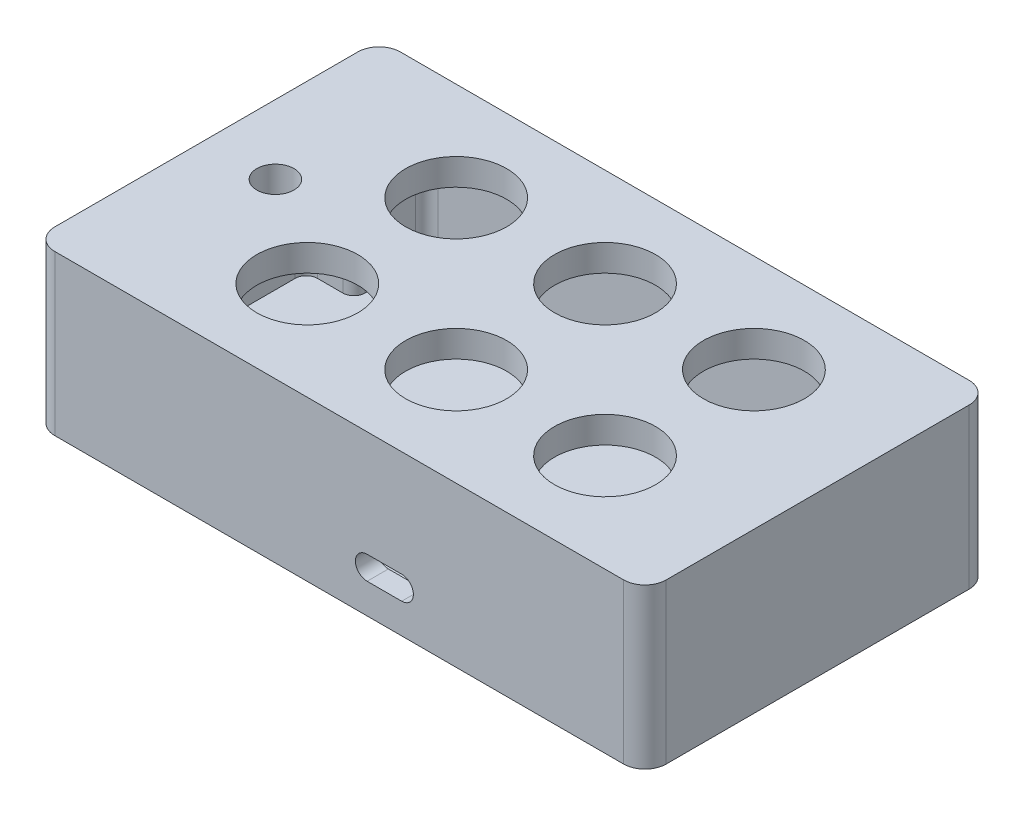
from build123d import *

# Parameters (mm, degrees)
SKETCH1_W           = 115
SKETCH1_H           = 65
SKETCH1_R           = 2.1
BOSS_EXTRUDE1_DEPTH = 22
BOSS_EXTRUDE4_START = 3
SKETCH6_W           = 115
SKETCH6_H           = 65
SKETCH6_R           = 2.1
BOSS_EXTRUDE4_DEPTH = 3
SKETCH7_W           = 115
SKETCH7_H           = 65
BOSS_EXTRUDE5_DEPTH = 5
FILLET1_R           = 4
CUT_EXTRUDE1_REACH  = 137.462
SKETCH4_R           = 9.5
SKETCH4_R_2         = 3.5
CUT_EXTRUDE2_REACH  = 136.83


with BuildPart() as part:
    # Sketch1 → Boss-Extrude1 (new body)
    with BuildSketch(Plane(origin=(0, 0, 0), x_dir=(1, 0, 0), z_dir=(0, 1, 0))):
        with Locations((57.5, 32.5)):
            Rectangle(SKETCH1_W, SKETCH1_H)
        with Locations((108.9, 50.001511105)):
            Circle(SKETCH1_R, mode=Mode.SUBTRACT)
        with Locations((110.685057222, 6.404275632)):
            Circle(SKETCH1_R, mode=Mode.SUBTRACT)
        with Locations((7.785057222, 14.601511105)):
            Circle(SKETCH1_R, mode=Mode.SUBTRACT)
        with Locations((7.785057222, 55.601511105)):
            Circle(SKETCH1_R, mode=Mode.SUBTRACT)
        with BuildLine():
            Line((6.1, 47.31447682), (10.861715208, 47.31447682))
            ThreePointArc((10.861715208, 47.31447682), (12.346639448, 47.929552579), (12.961715208, 49.41447682))
            Line((12.961715208, 49.41447682), (12.961715208, 58.9))
            ThreePointArc((12.961715208, 58.9), (13.576790967, 60.38492424), (15.061715208, 61))
            Line((15.061715208, 61), (100.622896336, 61))
            ThreePointArc((100.622896336, 61), (102.107820577, 60.38492424), (102.722896336, 58.9))
            Line((102.722896336, 58.9), (102.722896336, 44.601511105))
            ThreePointArc((102.722896336, 44.601511105), (103.337972096, 43.116586864), (104.822896336, 42.501511105))
            Line((104.822896336, 42.501511105), (108.9, 42.501511105))
            ThreePointArc((108.9, 42.501511105), (110.38492424, 41.886435345), (111, 40.401511105))
            Line((111, 40.401511105), (111, 14.601511105))
            ThreePointArc((111, 14.601511105), (110.38492424, 13.116586864), (108.9, 12.501511105))
            Line((108.9, 12.501511105), (105.206624477, 12.501511105))
            ThreePointArc((105.206624477, 12.501511105), (103.721700237, 11.886435345), (103.106624477, 10.401511105))
            Line((103.106624477, 10.401511105), (103.106624477, 6.1))
            ThreePointArc((103.106624477, 6.1), (102.491548718, 4.61507576), (101.006624477, 4))
            Line((101.006624477, 4), (18.206624477, 4))
            ThreePointArc((18.206624477, 4), (16.721700237, 4.61507576), (16.106624477, 6.1))
            Line((16.106624477, 6.1), (16.106624477, 19.183092127))
            ThreePointArc((16.106624477, 19.183092127), (15.491548718, 20.668016368), (14.006624477, 21.283092127))
            Line((14.006624477, 21.283092127), (6.1, 21.283092127))
            ThreePointArc((6.1, 21.283092127), (4.61507576, 21.898167887), (4, 23.383092127))
            Line((4, 23.383092127), (4, 45.21447682))
            ThreePointArc((4, 45.21447682), (4.61507576, 46.69940106), (6.1, 47.31447682))
        make_face(mode=Mode.SUBTRACT)
    extrude(amount=BOSS_EXTRUDE1_DEPTH)

    # Sketch6 → Boss-Extrude4 (add)
    with BuildSketch(Plane.XZ.offset(BOSS_EXTRUDE4_START)):
        with Locations((57.5, -32.5)):
            Rectangle(SKETCH6_W, SKETCH6_H)
        with Locations((7.785057222, -55.601511105)):
            Circle(SKETCH6_R, mode=Mode.SUBTRACT)
        with Locations((108.9, -50.001511105)):
            Circle(SKETCH6_R, mode=Mode.SUBTRACT)
        with Locations((7.785057222, -14.601511105)):
            Circle(SKETCH6_R, mode=Mode.SUBTRACT)
        with Locations((110.685057222, -6.404275632)):
            Circle(SKETCH6_R, mode=Mode.SUBTRACT)
    extrude(amount=-BOSS_EXTRUDE4_DEPTH)

    # Sketch7 → Boss-Extrude5 (add)
    with BuildSketch(Plane(origin=(0, 22, 0), x_dir=(1, 0, 0), z_dir=(0, 1, 0))):
        with Locations((57.5, 32.5)):
            Rectangle(SKETCH7_W, SKETCH7_H)
    extrude(amount=BOSS_EXTRUDE5_DEPTH)

    # Fillet1
    fillet1_edges = [part.edges().sort_by_distance(p)[0] for p in [
        (0, 12, -65),
        (115, 12, -65),
        (115, 12, 0),
        (0, 12, 0),
    ]]
    fillet(fillet1_edges, radius=FILLET1_R)

    # Sketch4 → Cut-Extrude1 (cut, up to next)
    with BuildSketch(Plane(origin=(0, 27, 0), x_dir=(1, 0, 0), z_dir=(0, 1, 0)), mode=Mode.PRIVATE) as cut_extrude1_sk1:
        with Locations((33, 46.5)):
            Circle(SKETCH4_R)
    cut_extrude1_tool1 = extrude(cut_extrude1_sk1.sketch, amount=-CUT_EXTRUDE1_REACH, mode=Mode.PRIVATE) & part.part
    # Sketch4 → Cut-Extrude1 (cut, up to next)
    with BuildSketch(Plane(origin=(0, 27, 0), x_dir=(1, 0, 0), z_dir=(0, 1, 0)), mode=Mode.PRIVATE) as cut_extrude1_sk2:
        with Locations((33, 18.5)):
            Circle(SKETCH4_R)
    cut_extrude1_tool2 = extrude(cut_extrude1_sk2.sketch, amount=-CUT_EXTRUDE1_REACH, mode=Mode.PRIVATE) & part.part
    # Sketch4 → Cut-Extrude1 (cut, up to next)
    with BuildSketch(Plane(origin=(0, 27, 0), x_dir=(1, 0, 0), z_dir=(0, 1, 0)), mode=Mode.PRIVATE) as cut_extrude1_sk3:
        with Locations((61, 46.5)):
            Circle(SKETCH4_R)
    cut_extrude1_tool3 = extrude(cut_extrude1_sk3.sketch, amount=-CUT_EXTRUDE1_REACH, mode=Mode.PRIVATE) & part.part
    # Sketch4 → Cut-Extrude1 (cut, up to next)
    with BuildSketch(Plane(origin=(0, 27, 0), x_dir=(1, 0, 0), z_dir=(0, 1, 0)), mode=Mode.PRIVATE) as cut_extrude1_sk4:
        with Locations((89, 46.5)):
            Circle(SKETCH4_R)
    cut_extrude1_tool4 = extrude(cut_extrude1_sk4.sketch, amount=-CUT_EXTRUDE1_REACH, mode=Mode.PRIVATE) & part.part
    # Sketch4 → Cut-Extrude1 (cut, up to next)
    with BuildSketch(Plane(origin=(0, 27, 0), x_dir=(1, 0, 0), z_dir=(0, 1, 0)), mode=Mode.PRIVATE) as cut_extrude1_sk5:
        with Locations((61, 18.5)):
            Circle(SKETCH4_R)
    cut_extrude1_tool5 = extrude(cut_extrude1_sk5.sketch, amount=-CUT_EXTRUDE1_REACH, mode=Mode.PRIVATE) & part.part
    # Sketch4 → Cut-Extrude1 (cut, up to next)
    with BuildSketch(Plane(origin=(0, 27, 0), x_dir=(1, 0, 0), z_dir=(0, 1, 0)), mode=Mode.PRIVATE) as cut_extrude1_sk6:
        with Locations((89, 18.5)):
            Circle(SKETCH4_R)
    cut_extrude1_tool6 = extrude(cut_extrude1_sk6.sketch, amount=-CUT_EXTRUDE1_REACH, mode=Mode.PRIVATE) & part.part
    # Sketch4 → Cut-Extrude1 (cut, up to next)
    with BuildSketch(Plane(origin=(0, 27, 0), x_dir=(1, 0, 0), z_dir=(0, 1, 0)), mode=Mode.PRIVATE) as cut_extrude1_sk7:
        with Locations((13, 32.5)):
            Circle(SKETCH4_R_2)
    cut_extrude1_tool7 = extrude(cut_extrude1_sk7.sketch, amount=-CUT_EXTRUDE1_REACH, mode=Mode.PRIVATE) & part.part
    add(cut_extrude1_tool1.solids().sort_by_distance((33, 27, -46.5))[0], mode=Mode.SUBTRACT)
    add(cut_extrude1_tool2.solids().sort_by_distance((33, 27, -18.5))[0], mode=Mode.SUBTRACT)
    add(cut_extrude1_tool3.solids().sort_by_distance((61, 27, -46.5))[0], mode=Mode.SUBTRACT)
    add(cut_extrude1_tool4.solids().sort_by_distance((89, 27, -46.5))[0], mode=Mode.SUBTRACT)
    add(cut_extrude1_tool5.solids().sort_by_distance((61, 27, -18.5))[0], mode=Mode.SUBTRACT)
    add(cut_extrude1_tool6.solids().sort_by_distance((89, 27, -18.5))[0], mode=Mode.SUBTRACT)
    add(cut_extrude1_tool7.solids().sort_by_distance((13, 27, -32.5))[0], mode=Mode.SUBTRACT)

    # Sketch5 → Cut-Extrude2 (cut, up to next)
    with BuildSketch(Plane.XY, mode=Mode.PRIVATE) as cut_extrude2_sk1:
        with BuildLine():
            Line((62.75, 7.055), (69.25, 7.055))
            ThreePointArc((69.25, 7.055), (71.45, 4.855), (69.25, 2.655))
            Line((69.25, 2.655), (62.75, 2.655))
            ThreePointArc((62.75, 2.655), (60.55, 4.855), (62.75, 7.055))
        make_face()
    cut_extrude2_tool1 = extrude(cut_extrude2_sk1.sketch, amount=-CUT_EXTRUDE2_REACH, mode=Mode.PRIVATE) & part.part
    add(cut_extrude2_tool1.solids().sort_by_distance((66, 4.855, 0))[0], mode=Mode.SUBTRACT)


solid = part.part
